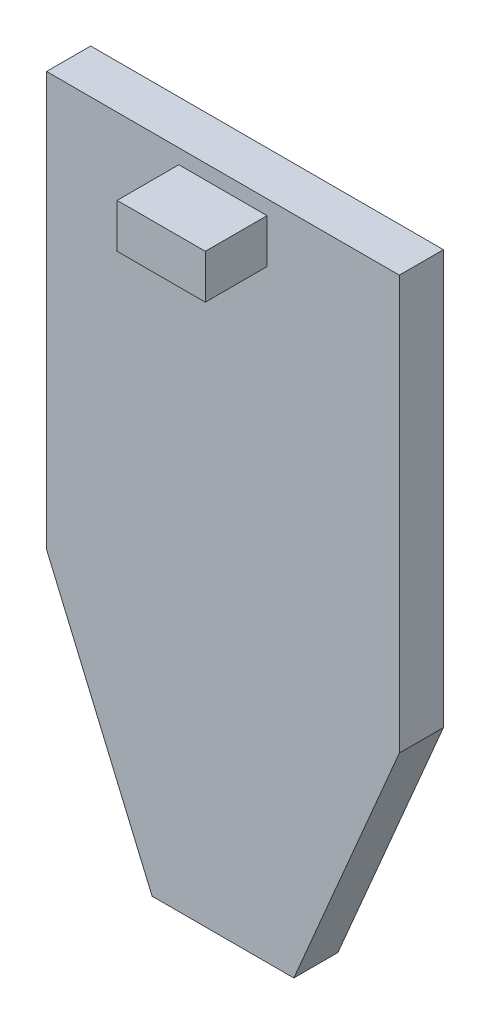
from build123d import *

# Parameters (mm, degrees)
BOSS_EXTRUDE1_DEPTH = 1
SKETCH2_W           = 2
SKETCH2_H           = 1
BOSS_EXTRUDE2_DEPTH = 1.4


with BuildPart() as part:
    # Sketch1 → Boss-Extrude1 (new body)
    with BuildSketch(Plane.XY):
        Polygon((-4, 6.562771437), (4, 6.562771437), (4, -2.823087523), (1.607040609, -8.437228563), (-1.607040609, -8.437228563), (-4, -2.823087523), align=None)
    extrude(amount=BOSS_EXTRUDE1_DEPTH)

    # Sketch2 → Boss-Extrude2 (add)
    with BuildSketch(Plane.XY.offset(1)):
        with Locations((0, 5.731176547)):
            Rectangle(SKETCH2_W, SKETCH2_H)
    extrude(amount=BOSS_EXTRUDE2_DEPTH)


solid = part.part
